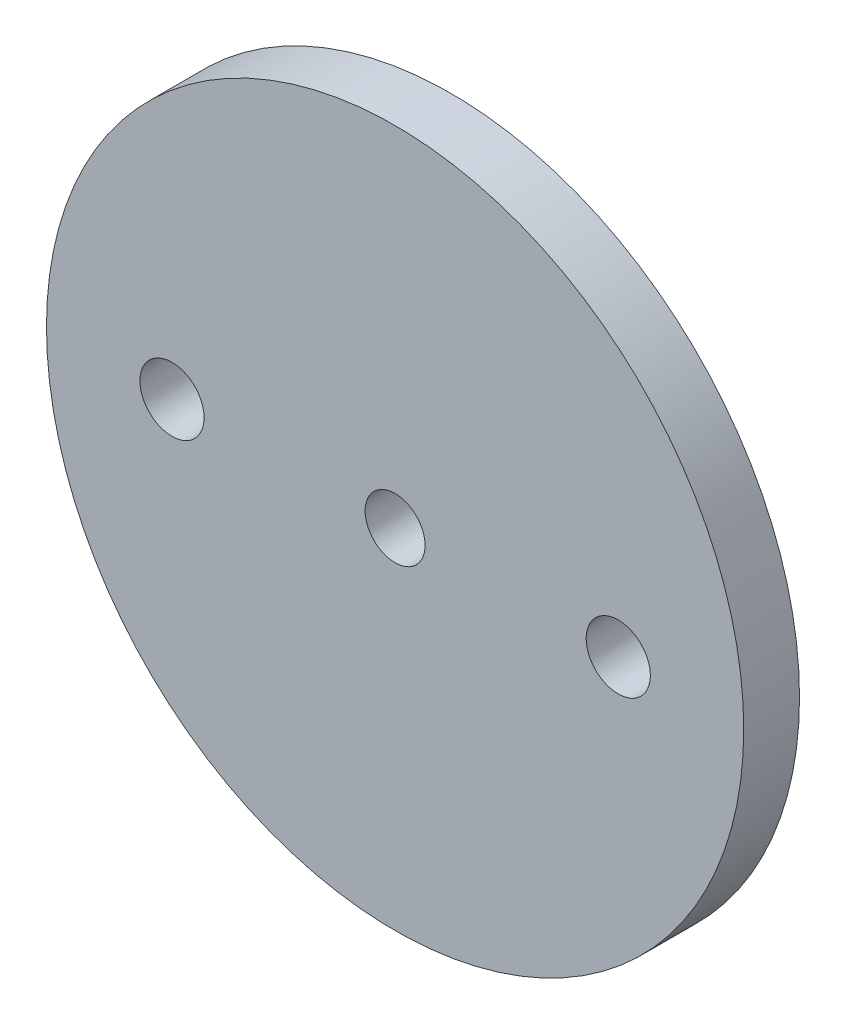
from build123d import *

# Parameters (mm, degrees)
SKETCH1_R           = 12.5
SKETCH1_R_2         = 1.075
SKETCH1_R_3         = 1.15
BOSS_EXTRUDE1_DEPTH = 2


with BuildPart() as part:
    # Sketch1 → Boss-Extrude1 (new body)
    with BuildSketch(Plane.XY):
        Circle(SKETCH1_R)
        Circle(SKETCH1_R_2, mode=Mode.SUBTRACT)
        with Locations((-8, 0)):
            Circle(SKETCH1_R_3, mode=Mode.SUBTRACT)
        with Locations((8, 0)):
            Circle(SKETCH1_R_3, mode=Mode.SUBTRACT)
    extrude(amount=BOSS_EXTRUDE1_DEPTH)


solid = part.part
